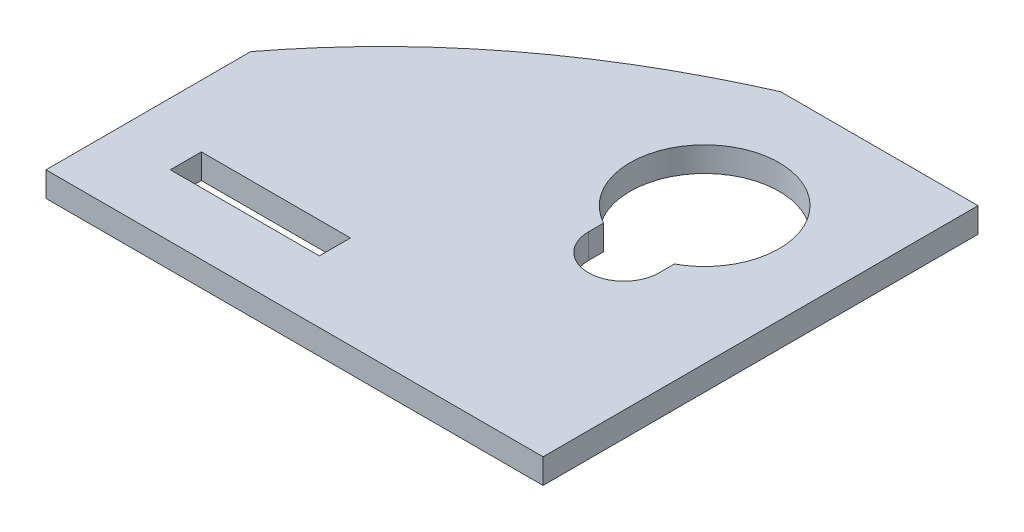
from build123d import *

# Parameters (mm, degrees)
ESQUISSE1_W             = 40
ESQUISSE1_H             = 35
ESQUISSE1_W_2           = 12
ESQUISSE1_H_2           = 2.5
BOSS_EXTRU_1_DEPTH      = 2
ENL_V_MAT_EXTRU_1_DEPTH = 10


with BuildPart() as part:
    # Esquisse1 → Boss.-Extru.1 (new body)
    with BuildSketch(Plane(origin=(0, 0, 0), x_dir=(1, 0, 0), z_dir=(0, 1, 0))):
        Rectangle(ESQUISSE1_W, ESQUISSE1_H)
        with BuildLine():
            Line((6.15, 1.220085228), (6.15, 0))
            ThreePointArc((6.15, 0), (9, -2.85), (11.85, 0))
            Line((11.85, 0), (11.85, 1.220085228))
            ThreePointArc((11.85, 1.220085228), (9, 12.5), (6.15, 1.220085228))
        make_face(mode=Mode.SUBTRACT)
        with Locations((-9, -11.25)):
            Rectangle(ESQUISSE1_W_2, ESQUISSE1_H_2, mode=Mode.SUBTRACT)
    extrude(amount=BOSS_EXTRU_1_DEPTH)

    # Esquisse2 → Enlèv. mat.-Extru.1 (cut)
    with BuildSketch(Plane(origin=(0, 2, 0), x_dir=(1, 0, 0), z_dir=(0, 1, 0))):
        with BuildLine():
            Line((-28.745227889, -17.5), (-25.633077883, 26.552925175))
            Line((-25.633077883, 26.552925175), (4.116600537, 17.5))
            add(Edge.make_bspline(
                [(4.116600537, 17.5), (-20.262864911, 6.720677368), (-28.745227889, -17.5)],
                knots=[0, 0, 0, 1, 1, 1], degree=2))
        make_face()
    extrude(amount=-ENL_V_MAT_EXTRU_1_DEPTH, mode=Mode.SUBTRACT)


solid = part.part
